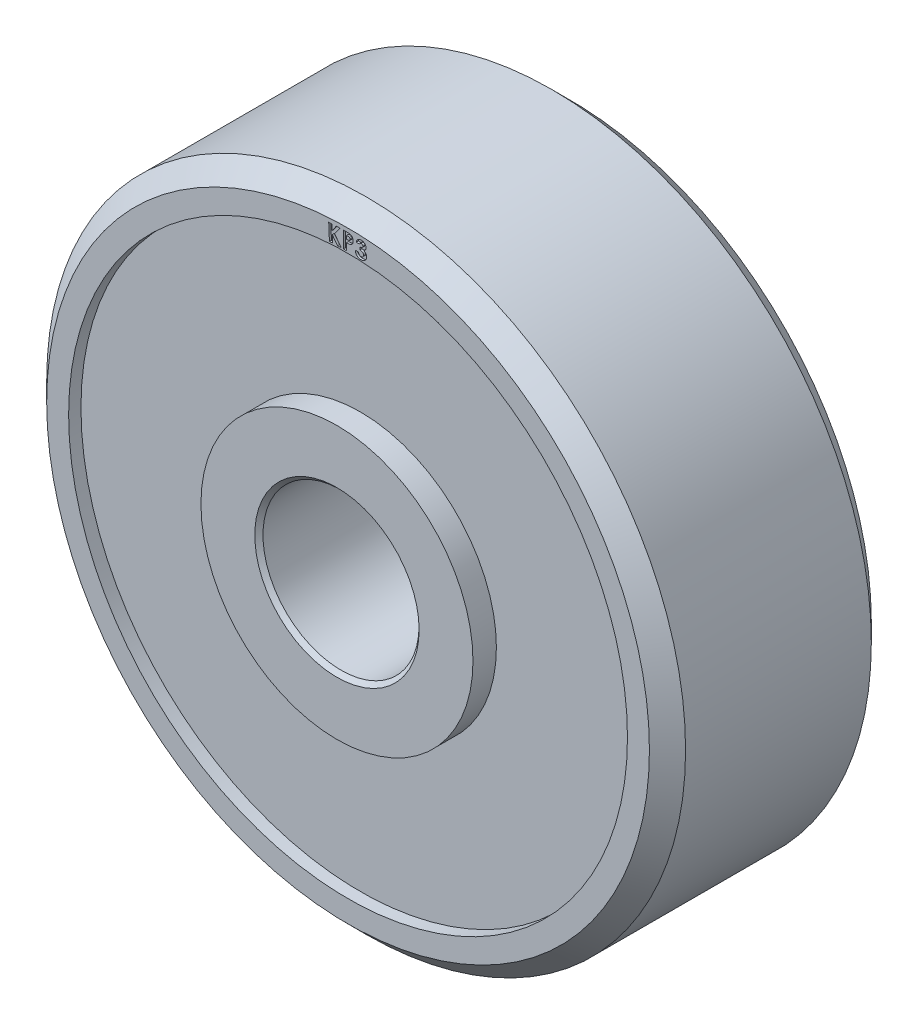
from build123d import *

# Parameters (mm, degrees)
CUT_EXTRUDE1_DEPTH = 0.0635


with BuildPart() as part:
    # Sketch1 → Revolve1 (revolve)
    with BuildSketch(Plane(origin=(0, 0, 0), x_dir=(0, 0, -1), z_dir=(1, 0, 0))):
        Polygon((-3.7719, 2.54), (-3.7719, 4.2037), (-3.048, 4.2037), (-3.048, 8.636), (-3.429, 8.636), (-3.429, 9.31418), (-2.8702, 9.87298), (2.8702, 9.87298), (3.429, 9.31418), (3.429, 8.636), (3.048, 8.636), (3.048, 4.2037), (3.7719, 4.2037), (3.7719, 2.54), (3.6449, 2.413), (-3.6449, 2.413), align=None)
    revolve(axis=Axis((0, 0, 0), (0, 0, -1)))

    # Sketch2 → Cut-Extrude1 (cut)
    with BuildSketch(Plane.XY.offset(3.429)):
        Polygon((-0.598105301, 9.171397743), (-0.500921808, 9.175671782), (-0.493289596, 9.001860884), (-0.363847288, 9.181675788), (-0.248142961, 9.186763929), (-0.414830461, 8.95372707), (-0.208862513, 8.682223865), (-0.322938634, 8.677237487), (-0.488608506, 8.894704634), (-0.478839276, 8.670419378), (-0.576022769, 8.666145339), align=None)
        with BuildLine():
            Line((-0.140250289, 9.189681026), (-0.038283943, 9.189477501))
            add(Edge.make_bspline(
                [(-0.038283943, 9.189477501), (-0.031635033, 9.18940443), (-0.018808295, 9.189263465), (-0.000275184, 9.1885967), (0.01682291, 9.187338715), (0.032496821, 9.185834063), (0.046673754, 9.183533617), (0.059441729, 9.180975541), (0.070752263, 9.177808175), (0.080839209, 9.174277868), (0.08983337, 9.169926327), (0.09832245, 9.165301159), (0.10628117, 9.159978019), (0.113742281, 9.154063657), (0.120686016, 9.147495011), (0.127181542, 9.140386824), (0.133234659, 9.132721381), (0.138698355, 9.12445894), (0.143696005, 9.115755285), (0.14800719, 9.106538248), (0.151507621, 9.096873261), (0.154499895, 9.086822544), (0.156839923, 9.07635432), (0.158457748, 9.065437632), (0.159368962, 9.054114913), (0.159484349, 9.046434518), (0.15954298, 9.042531988)],
                knots=[0, 0, 0, 0, 1.9948e-05, 3.8482e-05, 5.5622e-05, 7.1378e-05, 8.5699e-05, 9.8692e-05, 0.00011042, 0.000120913, 0.000130701, 0.000140357, 0.000149897, 0.000159385, 0.000168888, 0.00017854, 0.000188251, 0.000198157, 0.00020823, 0.000218336, 0.000228639, 0.000239039, 0.000249779, 0.000260789, 0.000272121, 0.000283828, 0.000283828, 0.000283828, 0.000283828], degree=3))
            add(Edge.make_bspline(
                [(0.15954298, 9.042531988), (0.159474088, 9.038220738), (0.159338674, 9.02974659), (0.157999118, 9.017322573), (0.155740455, 9.005458066), (0.152706731, 8.994153705), (0.148836964, 8.983375045), (0.144039039, 8.973204435), (0.138416045, 8.963544754), (0.131886644, 8.95452676), (0.124674763, 8.946082956), (0.116816018, 8.938313342), (0.108307037, 8.931276731), (0.099208997, 8.92481604), (0.089462364, 8.919057879), (0.079108376, 8.913907216), (0.068120927, 8.909565121), (0.060509499, 8.907174901), (0.056660768, 8.905966283)],
                knots=[0, 0, 0, 0, 1.293e-05, 2.5416e-05, 3.7431e-05, 4.9131e-05, 6.0495e-05, 7.1739e-05, 8.2822e-05, 9.3977e-05, 0.000105092, 0.000116102, 0.000127086, 0.000138182, 0.000149544, 0.000161012, 0.000172842, 0.000184942, 0.000184942, 0.000184942, 0.000184942], degree=3))
            add(Edge.make_bspline(
                [(0.056660768, 8.905966283), (0.054123461, 8.905324754), (0.048579037, 8.90392291), (0.039462824, 8.902374058), (0.028938159, 8.90104703), (0.016979166, 8.900117127), (0.00362007, 8.899146787), (-0.011210408, 8.89856852), (-0.027428029, 8.89829074), (-0.038724796, 8.898252285), (-0.044593238, 8.898232308)],
                knots=[0, 0, 0, 0, 7.849e-06, 1.7151e-05, 2.7716e-05, 3.9666e-05, 5.3129e-05, 6.7898e-05, 8.4183e-05, 0.000101788, 0.000101788, 0.000101788, 0.000101788], degree=3))
            Line((-0.044593238, 8.898232308), (-0.045000289, 8.684225097))
            Line((-0.045000289, 8.684225097), (-0.141166155, 8.684428622))
            Line((-0.141166155, 8.684428622), (-0.140250289, 9.189681026))
        make_face()
        with BuildLine():
            Line((-0.044491475, 8.991955866), (-0.013962629, 8.991955866))
            add(Edge.make_bspline(
                [(-0.013962629, 8.991955866), (-0.008397832, 8.992000478), (0.001790994, 8.99208216), (0.015721939, 8.992981275), (0.026920615, 8.994328786), (0.035794151, 8.996564152), (0.042780648, 8.999805284), (0.048848743, 9.00358624), (0.054059554, 9.008350968), (0.058563323, 9.013841954), (0.062179518, 9.020120727), (0.064680724, 9.027083908), (0.06627537, 9.034658567), (0.066444249, 9.039911613), (0.066531762, 9.042633751)],
                knots=[0, 0, 0, 0, 1.6692e-05, 3.0562e-05, 4.1859e-05, 5.0499e-05, 5.7877e-05, 6.4878e-05, 7.1867e-05, 7.8955e-05, 8.6112e-05, 9.3485e-05, 0.000101069, 0.000109225, 0.000109225, 0.000109225, 0.000109225], degree=3))
            add(Edge.make_bspline(
                [(0.066531762, 9.042633751), (0.066482444, 9.044977462), (0.06638687, 9.04951935), (0.065379159, 9.056134605), (0.063510867, 9.062227112), (0.061092053, 9.067906569), (0.057892891, 9.073043573), (0.053983979, 9.077706371), (0.04924533, 9.081761928), (0.045730291, 9.084087951), (0.043940416, 9.085272372)],
                knots=[0, 0, 0, 0, 7.028e-06, 1.362e-05, 1.9995e-05, 2.6101e-05, 3.2088e-05, 3.8082e-05, 4.4285e-05, 5.0721e-05, 5.0721e-05, 5.0721e-05, 5.0721e-05], degree=3))
            add(Edge.make_bspline(
                [(0.043940416, 9.085272372), (0.042430796, 9.086088737), (0.039229013, 9.087820181), (0.033743663, 9.089808968), (0.027411258, 9.091525118), (0.020163105, 9.092914309), (0.012048346, 9.09404809), (0.003038188, 9.094673567), (-0.006798694, 9.095230208), (-0.013656368, 9.095306998), (-0.017219039, 9.095346892)],
                knots=[0, 0, 0, 0, 5.143e-06, 1.0907e-05, 1.745e-05, 2.4814e-05, 3.3032e-05, 4.2015e-05, 5.1899e-05, 6.2586e-05, 6.2586e-05, 6.2586e-05, 6.2586e-05], degree=3))
            Line((-0.017219039, 9.095346892), (-0.04428795, 9.095346892))
            Line((-0.04428795, 9.095346892), (-0.044491475, 8.991955866))
        make_face(mode=Mode.SUBTRACT)
        with BuildLine():
            Line((0.346270655, 9.06023752), (0.253870014, 9.063595693))
            add(Edge.make_bspline(
                [(0.253870014, 9.063595693), (0.254731735, 9.068118659), (0.256428252, 9.077023265), (0.259853, 9.089937058), (0.264171991, 9.102090029), (0.269128026, 9.113558375), (0.274984598, 9.124297383), (0.281559292, 9.134384408), (0.289016564, 9.143702358), (0.29455927, 9.149325683), (0.297322738, 9.152129347)],
                knots=[0, 0, 0, 0, 1.3811e-05, 2.719e-05, 4.0031e-05, 5.2472e-05, 6.463e-05, 7.6682e-05, 8.8554e-05, 0.000100358, 0.000100358, 0.000100358, 0.000100358], degree=3))
            add(Edge.make_bspline(
                [(0.297322738, 9.152129347), (0.301356399, 9.15577656), (0.309309173, 9.162967415), (0.322354884, 9.172172141), (0.336084939, 9.179829424), (0.350467583, 9.18612903), (0.365629693, 9.190642345), (0.381391309, 9.193834704), (0.397862241, 9.195505013), (0.409055183, 9.195353809), (0.414757033, 9.195276783)],
                knots=[0, 0, 0, 0, 1.6303e-05, 3.2143e-05, 4.777e-05, 6.3404e-05, 7.9145e-05, 9.5131e-05, 0.000111596, 0.000128692, 0.000128692, 0.000128692, 0.000128692], degree=3))
            add(Edge.make_bspline(
                [(0.414757033, 9.195276783), (0.419818364, 9.194948003), (0.429783765, 9.194300658), (0.44439036, 9.191998471), (0.458284438, 9.188248146), (0.471604991, 9.183543971), (0.484133135, 9.177356603), (0.496040582, 9.170094067), (0.507267816, 9.161621807), (0.517661726, 9.152008614), (0.527039476, 9.141578012), (0.535370108, 9.130726385), (0.542182432, 9.119358456), (0.547809347, 9.107635773), (0.551926217, 9.09542383), (0.554841168, 9.082819662), (0.556255244, 9.069802903), (0.55622345, 9.061020393), (0.556207354, 9.056574059)],
                knots=[0, 0, 0, 0, 1.5212e-05, 2.9951e-05, 4.4267e-05, 5.8334e-05, 7.2261e-05, 8.6101e-05, 0.000100124, 0.000114383, 0.000128505, 0.000142162, 0.000155356, 0.000168193, 0.000181097, 0.000193934, 0.000206936, 0.000220269, 0.000220269, 0.000220269, 0.000220269], degree=3))
            add(Edge.make_bspline(
                [(0.556207354, 9.056574059), (0.55580202, 9.051087569), (0.554998325, 9.040208973), (0.55078647, 9.02442963), (0.544379528, 9.009473535), (0.535837298, 8.995412989), (0.525076914, 8.982505843), (0.512158979, 8.971059659), (0.497324783, 8.960842905), (0.48627563, 8.9555143), (0.480597578, 8.952775982)],
                knots=[0, 0, 0, 0, 1.6475e-05, 3.2666e-05, 4.8714e-05, 6.5155e-05, 8.1845e-05, 9.8925e-05, 0.000116792, 0.000135679, 0.000135679, 0.000135679, 0.000135679], degree=3))
            add(Edge.make_bspline(
                [(0.480597578, 8.952775982), (0.484316626, 8.951440166), (0.491622242, 8.94881612), (0.502031834, 8.944005757), (0.511759925, 8.938545311), (0.520963419, 8.932608366), (0.529370297, 8.925845217), (0.537219049, 8.918584581), (0.544291396, 8.910619157), (0.550830967, 8.902183049), (0.556626637, 8.89328563), (0.561512919, 8.883916213), (0.565729441, 8.874290081), (0.568980382, 8.864224827), (0.571419797, 8.853842136), (0.573042821, 8.843089677), (0.573884362, 8.83199686), (0.573768964, 8.824488129), (0.573710559, 8.820687841)],
                knots=[0, 0, 0, 0, 1.1851e-05, 2.328e-05, 3.435e-05, 4.5301e-05, 5.6092e-05, 6.6676e-05, 7.7341e-05, 8.8007e-05, 9.8677e-05, 0.000109146, 0.000119676, 0.000130167, 0.00014083, 0.000151638, 0.00016276, 0.000174158, 0.000174158, 0.000174158, 0.000174158], degree=3))
            add(Edge.make_bspline(
                [(0.573710559, 8.820687841), (0.5733382, 8.815114038), (0.572605064, 8.804139786), (0.569756361, 8.788089754), (0.565245942, 8.772765741), (0.559079087, 8.758208577), (0.551546414, 8.744231726), (0.542296395, 8.731077014), (0.531552159, 8.718609363), (0.519403699, 8.707013189), (0.506156409, 8.69641261), (0.491864326, 8.687360521), (0.476787165, 8.67979207), (0.460973193, 8.673610749), (0.444262617, 8.669184438), (0.426797491, 8.666160406), (0.40851562, 8.664422474), (0.396069889, 8.664664024), (0.389723379, 8.6647872)],
                knots=[0, 0, 0, 0, 1.675e-05, 3.2979e-05, 4.8789e-05, 6.457e-05, 8.0326e-05, 9.6332e-05, 0.000112712, 0.000129626, 0.000146647, 0.000163529, 0.000180277, 0.00019719, 0.000214371, 0.000232039, 0.000250327, 0.000269356, 0.000269356, 0.000269356, 0.000269356], degree=3))
            add(Edge.make_bspline(
                [(0.389723379, 8.6647872), (0.383742107, 8.665116437), (0.372027346, 8.665761272), (0.354945616, 8.668607755), (0.338752339, 8.672614661), (0.323434042, 8.678040325), (0.309053282, 8.684877463), (0.295550757, 8.693057844), (0.282933024, 8.702569015), (0.271390677, 8.713467082), (0.260868807, 8.725456972), (0.251708494, 8.738550165), (0.243801853, 8.752532114), (0.237414206, 8.767547835), (0.232173231, 8.783426823), (0.228477722, 8.800311249), (0.225970636, 8.818107312), (0.225443052, 8.830312882), (0.225172899, 8.836562841)],
                knots=[0, 0, 0, 0, 1.7959e-05, 3.5174e-05, 5.1859e-05, 6.7952e-05, 8.3838e-05, 9.9545e-05, 0.000115237, 0.000131148, 0.000147087, 0.00016301, 0.000179003, 0.000195184, 0.000211886, 0.000229094, 0.000246968, 0.000265726, 0.000265726, 0.000265726, 0.000265726], degree=3))
            Line((0.225172899, 8.836562841), (0.320321136, 8.833102905))
            add(Edge.make_bspline(
                [(0.320321136, 8.833102905), (0.32075063, 8.829906842), (0.321582564, 8.823716033), (0.323548815, 8.814775411), (0.325998141, 8.806459085), (0.32879004, 8.798647132), (0.332260157, 8.791550448), (0.336188517, 8.785081316), (0.340425884, 8.779086022), (0.346936998, 8.772125707), (0.356143413, 8.764715148), (0.368909372, 8.758384557), (0.383006984, 8.754026224), (0.393014234, 8.753292036), (0.398169693, 8.752913802)],
                knots=[0, 0, 0, 0, 9.671e-06, 1.8733e-05, 2.7428e-05, 3.567e-05, 4.3589e-05, 5.1076e-05, 5.8363e-05, 6.5565e-05, 7.9614e-05, 9.354e-05, 0.000108093, 0.000123556, 0.000123556, 0.000123556, 0.000123556], degree=3))
            add(Edge.make_bspline(
                [(0.398169693, 8.752913802), (0.400920214, 8.752847157), (0.406333279, 8.752715998), (0.414247649, 8.753662365), (0.421912689, 8.754883155), (0.429153478, 8.757058351), (0.436142555, 8.759813544), (0.442656713, 8.763411726), (0.449005599, 8.76748442), (0.454820422, 8.772362237), (0.460170224, 8.777733564), (0.465000584, 8.78338607), (0.469010937, 8.789499065), (0.47231616, 8.795899158), (0.47518995, 8.802552115), (0.477022694, 8.80963195), (0.478430748, 8.816972709), (0.478720638, 8.822004001), (0.47886761, 8.824554828)],
                knots=[0, 0, 0, 0, 8.243e-06, 1.6222e-05, 2.3868e-05, 3.15e-05, 3.8851e-05, 4.6363e-05, 5.3786e-05, 6.1448e-05, 6.9075e-05, 7.6515e-05, 8.3712e-05, 9.095e-05, 9.8112e-05, 0.000105395, 0.00011284, 0.000120497, 0.000120497, 0.000120497, 0.000120497], degree=3))
            add(Edge.make_bspline(
                [(0.47886761, 8.824554828), (0.478909718, 8.827374049), (0.478992791, 8.83293596), (0.4777972, 8.841134245), (0.475765032, 8.849022522), (0.472806699, 8.856635047), (0.468778674, 8.863879576), (0.463856255, 8.870830512), (0.458011486, 8.877504536), (0.451171866, 8.883742388), (0.443577135, 8.889714441), (0.434950313, 8.894898455), (0.425485769, 8.899339075), (0.415194442, 8.903114382), (0.404078694, 8.906279098), (0.392063745, 8.908673641), (0.379216136, 8.910426296), (0.37035975, 8.910974876), (0.365809116, 8.911256751)],
                knots=[0, 0, 0, 0, 8.447e-06, 1.6665e-05, 2.476e-05, 3.2848e-05, 4.1092e-05, 4.9562e-05, 5.836e-05, 6.7649e-05, 7.7297e-05, 8.7297e-05, 9.7767e-05, 0.000108618, 0.00012015, 0.000132404, 0.000145342, 0.000159016, 0.000159016, 0.000159016, 0.000159016], degree=3))
            Line((0.365809116, 8.911256751), (0.368862001, 8.993684635))
            add(Edge.make_bspline(
                [(0.368862001, 8.993684635), (0.374295082, 8.993989528), (0.384476354, 8.994560878), (0.398626285, 8.996364743), (0.410659099, 8.998789964), (0.420722436, 9.002176313), (0.429151576, 9.006466404), (0.436509462, 9.011414566), (0.442946751, 9.017098892), (0.448380771, 9.023559115), (0.452704793, 9.030544873), (0.456056649, 9.037834462), (0.458143779, 9.045475549), (0.45859397, 9.05069381), (0.458820334, 9.053317648)],
                knots=[0, 0, 0, 0, 1.632e-05, 3.0584e-05, 4.2759e-05, 5.3089e-05, 6.2328e-05, 7.1049e-05, 7.9627e-05, 8.8005e-05, 9.6278e-05, 0.000104203, 0.000112004, 0.000119893, 0.000119893, 0.000119893, 0.000119893], degree=3))
            add(Edge.make_bspline(
                [(0.458820334, 9.053317648), (0.45880289, 9.056626011), (0.458768891, 9.063074145), (0.456152924, 9.072310538), (0.451944314, 9.080797075), (0.445760103, 9.088162726), (0.43820033, 9.094422841), (0.429341602, 9.099195826), (0.419192375, 9.102041546), (0.412060847, 9.102657204), (0.408345975, 9.102977905)],
                knots=[0, 0, 0, 0, 9.884e-06, 1.9265e-05, 2.8503e-05, 3.8119e-05, 4.7878e-05, 5.7803e-05, 6.8077e-05, 7.9248e-05, 7.9248e-05, 7.9248e-05, 7.9248e-05], degree=3))
            add(Edge.make_bspline(
                [(0.408345975, 9.102977905), (0.404978196, 9.102957653), (0.398277294, 9.102917357), (0.388420756, 9.100805541), (0.379038052, 9.097057459), (0.370264356, 9.091898139), (0.362310613, 9.085509955), (0.355551909, 9.078023246), (0.350011229, 9.069594396), (0.347524941, 9.063375061), (0.346270655, 9.06023752)],
                knots=[0, 0, 0, 0, 1.0083e-05, 2.0062e-05, 3.002e-05, 4.0283e-05, 5.0486e-05, 6.0501e-05, 7.0437e-05, 8.0552e-05, 8.0552e-05, 8.0552e-05, 8.0552e-05], degree=3))
        make_face()
    extrude(amount=-CUT_EXTRUDE1_DEPTH, mode=Mode.SUBTRACT)


solid = part.part
